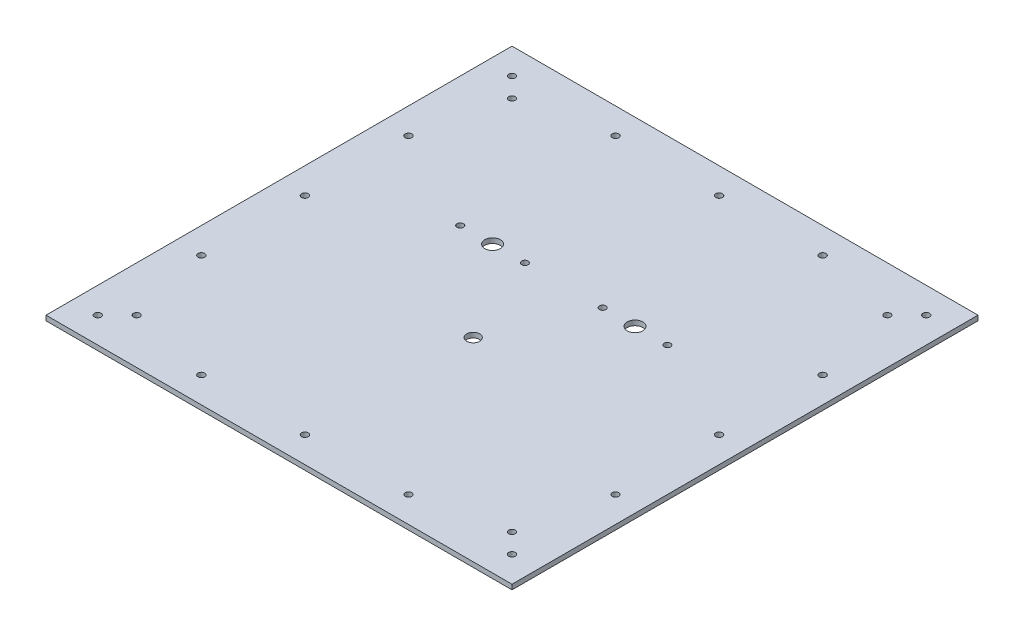
from build123d import *

# Parameters (mm, degrees)
SKETCH1_W           = 457.2
SKETCH1_H           = 457.2
BOSS_EXTRUDE1_DEPTH = 4.826
SKETCH2_R           = 7.62
SKETCH2_R_2         = 6.35
CUT_EXTRUDE1_DEPTH  = 25.4
SKETCH4_R           = 3.175
CUT_EXTRUDE2_DEPTH  = 5.08
SKETCH6_R           = 3.2639
CUT_EXTRUDE3_DEPTH  = 12.7
SKETCH8_R           = 3.175
CUT_EXTRUDE5_DEPTH  = 5.826


with BuildPart() as part:
    # Sketch1 → Boss-Extrude1 (new body)
    with BuildSketch(Plane(origin=(0, 0, 0), x_dir=(1, 0, 0), z_dir=(0, 1, 0))):
        Rectangle(SKETCH1_W, SKETCH1_H)
    extrude(amount=BOSS_EXTRUDE1_DEPTH)

    # Sketch2 → Cut-Extrude1 (cut)
    with BuildSketch(Plane(origin=(0, 4.826, 0), x_dir=(1, 0, 0), z_dir=(0, 1, 0))):
        with Locations((69.85, 50.8)):
            Circle(SKETCH2_R)
        with Locations((-69.85, 50.8)):
            Circle(SKETCH2_R)
        with Locations((0, -38.1)):
            Circle(SKETCH2_R_2)
    extrude(amount=-CUT_EXTRUDE1_DEPTH, mode=Mode.SUBTRACT)

    # Sketch4 → Cut-Extrude2 (cut)
    with BuildSketch(Plane(origin=(0, 4.826, 0), x_dir=(1, 0, 0), z_dir=(0, 1, 0))):
        with Locations((-184.15, 184.15)):
            Circle(SKETCH4_R)
        with Locations((184.15, 184.15)):
            Circle(SKETCH4_R)
        with Locations((184.15, -184.15)):
            Circle(SKETCH4_R)
        with Locations((-184.15, -184.15)):
            Circle(SKETCH4_R)
    extrude(amount=-CUT_EXTRUDE2_DEPTH, mode=Mode.SUBTRACT)

    # Sketch6 → Cut-Extrude3 (cut)
    with BuildSketch(Plane(origin=(0, 4.826, 0), x_dir=(1, 0, 0), z_dir=(0, 1, 0))):
        with Locations((203.2, -203.2)):
            Circle(SKETCH6_R)
        with Locations((-203.2, 203.2)):
            Circle(SKETCH6_R)
        with Locations((203.2, -101.6)):
            Circle(SKETCH6_R)
        with Locations((203.2, 0)):
            Circle(SKETCH6_R)
        with Locations((203.2, 101.6)):
            Circle(SKETCH6_R)
        with Locations((203.2, 203.2)):
            Circle(SKETCH6_R)
        with Locations((101.6, -203.2)):
            Circle(SKETCH6_R)
        with Locations((0, -203.2)):
            Circle(SKETCH6_R)
        with Locations((-101.6, -203.2)):
            Circle(SKETCH6_R)
        with Locations((-203.2, -203.2)):
            Circle(SKETCH6_R)
        with Locations((304.8, -203.2)):
            Circle(SKETCH6_R)
        with Locations((-101.6, 203.2)):
            Circle(SKETCH6_R)
        with Locations((406.4, -203.2)):
            Circle(SKETCH6_R)
        with Locations((0, 203.2)):
            Circle(SKETCH6_R)
        with Locations((508, -203.2)):
            Circle(SKETCH6_R)
        with Locations((101.6, 203.2)):
            Circle(SKETCH6_R)
        with Locations((203.2, -304.8)):
            Circle(SKETCH6_R)
        with Locations((-203.2, 101.6)):
            Circle(SKETCH6_R)
        with Locations((203.2, -406.4)):
            Circle(SKETCH6_R)
        with Locations((-203.2, 0)):
            Circle(SKETCH6_R)
        with Locations((203.2, -508)):
            Circle(SKETCH6_R)
        with Locations((-203.2, -101.6)):
            Circle(SKETCH6_R)
    extrude(amount=-CUT_EXTRUDE3_DEPTH, mode=Mode.SUBTRACT)

    # Sketch8 → Cut-Extrude5 (cut, through all)
    with BuildSketch(Plane(origin=(0, 4.826, 0), x_dir=(1, 0, 0), z_dir=(0, 1, 0))):
        with Locations((-101.6, 50.8)):
            Circle(SKETCH8_R)
        with Locations((-38.1, 50.8)):
            Circle(SKETCH8_R)
        with Locations((38.1, 50.8)):
            Circle(SKETCH8_R)
        with Locations((101.6, 50.8)):
            Circle(SKETCH8_R)
    extrude(amount=-CUT_EXTRUDE5_DEPTH, mode=Mode.SUBTRACT)


solid = part.part
